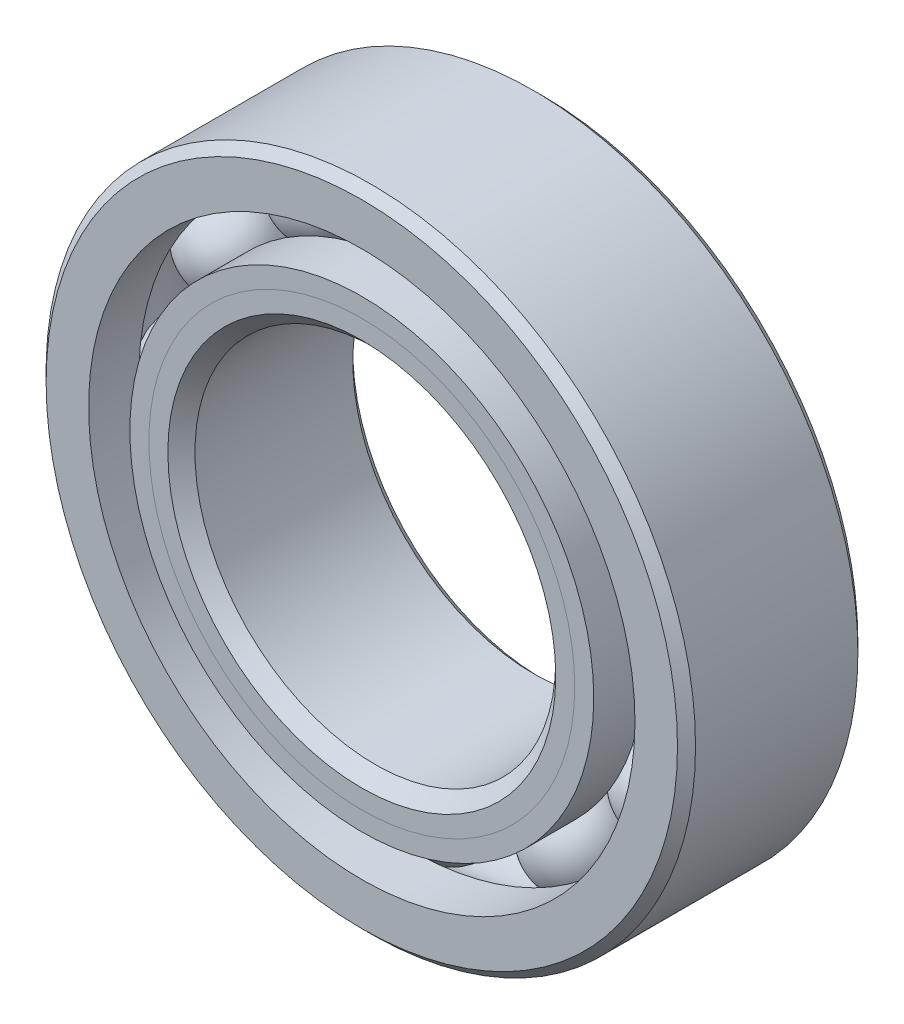
from build123d import *

# Parameters (mm, degrees)
CIRPATTERN1_COUNT = 12


with BuildPart() as part:
    # Sketch1 → Revolve1 (revolve)
    with BuildSketch(Plane(origin=(0, 0, 0), x_dir=(0, 0, -1), z_dir=(1, 0, 0))):
        with BuildLine():
            Line((3.571875, 14.2875), (-3.571875, 14.2875))
            Line((-3.571875, 14.2875), (-3.96875, 13.890625))
            Line((-3.96875, 13.890625), (-3.96875, 12.019642857))
            Line((-3.96875, 12.019642857), (-1.763888889, 12.019642857))
            ThreePointArc((-1.763888889, 12.019642857), (0, 13.095984856), (1.763888889, 12.019642857))
            Line((1.763888889, 12.019642857), (3.96875, 12.019642857))
            Line((3.96875, 12.019642857), (3.96875, 13.890625))
            Line((3.96875, 13.890625), (3.571875, 14.2875))
        make_face()
    revolve(axis=Axis((0, 0, 3.96875), (0, 0, -1)))


with BuildPart() as body_2:
    # Sketch2 → Revolve2 (revolve)
    with BuildSketch(Plane(origin=(0, 0, 0), x_dir=(0, 0, -1), z_dir=(1, 0, 0))):
        with BuildLine():
            Line((-3.96875, 10.205357143), (-1.763888889, 10.205357143))
            ThreePointArc((-1.763888889, 10.205357143), (-1.033176668, 9.419349638), (0, 9.129015144))
            Line((0, 9.129015144), (0, 8.533257572))
            Line((0, 8.533257572), (-3.132700214, 8.533257572))
            Line((-3.132700214, 8.533257572), (-3.96875, 9.369307357))
            Line((-3.96875, 9.369307357), (-3.96875, 10.205357143))
        make_face()
    revolve(axis=Axis((0, 0, 3.96875), (0, 0, -1)))


with BuildPart() as body_3:
    # Sketch3 → Revolve3 (revolve)
    with BuildSketch(Plane(origin=(0, 0, 0), x_dir=(0, 0, -1), z_dir=(1, 0, 0))):
        with BuildLine():
            Line((-3.96875, 9.369307357), (-3.132700214, 8.533257572))
            Line((-3.132700214, 8.533257572), (0, 8.533257572))
            Line((0, 8.533257572), (0, 9.129015144))
            ThreePointArc((0, 9.129015144), (1.033176668, 9.419349638), (1.763888889, 10.205357143))
            Line((1.763888889, 10.205357143), (3.96875, 10.205357143))
            Line((3.96875, 10.205357143), (3.96875, 8.334375))
            Line((3.96875, 8.334375), (3.571875, 7.9375))
            Line((3.571875, 7.9375), (-3.372992428, 7.9375))
            Line((-3.372992428, 7.9375), (-3.96875, 8.533257572))
            Line((-3.96875, 8.533257572), (-3.96875, 9.369307357))
        make_face()
    revolve(axis=Axis((0, 0, 3.96875), (0, 0, -1)))


with BuildPart() as body_4:
    # Sketch4 → Revolve4 (revolve)
    with BuildSketch(Plane(origin=(0, 0, 0), x_dir=(0, 0, -1), z_dir=(1, 0, 0))):
        with BuildLine():
            Line((-1.983484856, 11.1125), (1.983484856, 11.1125))
            ThreePointArc((1.983484856, 11.1125), (0, 13.095984856), (-1.983484856, 11.1125))
        make_face()
    revolve(axis=Axis((0, 11.1125, 1.983484856), (0, 0, -1)))


with BuildPart() as cirpattern1_1:
    # CirPattern1: pattern copy
    add(body_4.part.rotate(Axis((0, 0, -3.96875), (0, 0, 1)), 1 * 360 / CIRPATTERN1_COUNT))


with BuildPart() as cirpattern1_2:
    # CirPattern1: pattern copy
    add(body_4.part.rotate(Axis((0, 0, -3.96875), (0, 0, 1)), 2 * 360 / CIRPATTERN1_COUNT))


with BuildPart() as cirpattern1_3:
    # CirPattern1: pattern copy
    add(body_4.part.rotate(Axis((0, 0, -3.96875), (0, 0, 1)), 3 * 360 / CIRPATTERN1_COUNT))


with BuildPart() as cirpattern1_4:
    # CirPattern1: pattern copy
    add(body_4.part.rotate(Axis((0, 0, -3.96875), (0, 0, 1)), 4 * 360 / CIRPATTERN1_COUNT))


with BuildPart() as cirpattern1_5:
    # CirPattern1: pattern copy
    add(body_4.part.rotate(Axis((0, 0, -3.96875), (0, 0, 1)), 5 * 360 / CIRPATTERN1_COUNT))


with BuildPart() as cirpattern1_6:
    # CirPattern1: pattern copy
    add(body_4.part.rotate(Axis((0, 0, -3.96875), (0, 0, 1)), 6 * 360 / CIRPATTERN1_COUNT))


with BuildPart() as cirpattern1_7:
    # CirPattern1: pattern copy
    add(body_4.part.rotate(Axis((0, 0, -3.96875), (0, 0, 1)), 7 * 360 / CIRPATTERN1_COUNT))


with BuildPart() as cirpattern1_8:
    # CirPattern1: pattern copy
    add(body_4.part.rotate(Axis((0, 0, -3.96875), (0, 0, 1)), 8 * 360 / CIRPATTERN1_COUNT))


with BuildPart() as cirpattern1_9:
    # CirPattern1: pattern copy
    add(body_4.part.rotate(Axis((0, 0, -3.96875), (0, 0, 1)), 9 * 360 / CIRPATTERN1_COUNT))


with BuildPart() as cirpattern1_10:
    # CirPattern1: pattern copy
    add(body_4.part.rotate(Axis((0, 0, -3.96875), (0, 0, 1)), 10 * 360 / CIRPATTERN1_COUNT))


with BuildPart() as cirpattern1_11:
    # CirPattern1: pattern copy
    add(body_4.part.rotate(Axis((0, 0, -3.96875), (0, 0, 1)), 11 * 360 / CIRPATTERN1_COUNT))


solid = Compound([part.part, body_2.part, body_3.part, body_4.part, cirpattern1_1.part, cirpattern1_2.part, cirpattern1_3.part, cirpattern1_4.part, cirpattern1_5.part, cirpattern1_6.part, cirpattern1_7.part, cirpattern1_8.part, cirpattern1_9.part, cirpattern1_10.part, cirpattern1_11.part])
